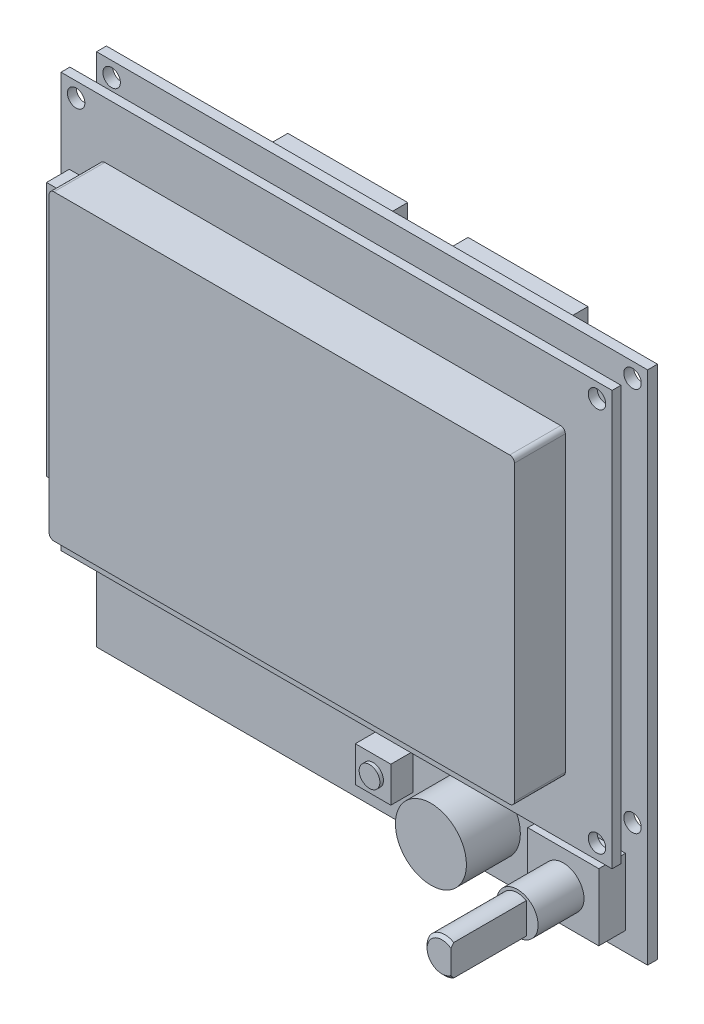
from build123d import *

# Parameters (mm, degrees)
SKETCH1_W            = 93.1
SKETCH1_H            = 87.1
SKETCH1_R            = 1.475
BOSS_EXTRUDE1_DEPTH  = 1.67
BOSS_EXTRUDE2_START  = 4.5
SKETCH2_W            = 93.1
SKETCH2_H            = 70
SKETCH2_R            = 1.475
BOSS_EXTRUDE2_DEPTH  = 1.5
BOSS_EXTRUDE3_DEPTH  = 8.6
SKETCH4_W            = 5.2
SKETCH4_H            = 43
BOSS_EXTRUDE4_DEPTH  = 3.85
SKETCH5_W            = 6
SKETCH5_H            = 6
BOSS_EXTRUDE5_DEPTH  = 3.78
SKETCH6_R            = 1.75
BOSS_EXTRUDE6_DEPTH  = 0.6
SKETCH7_R            = 6
BOSS_EXTRUDE7_DEPTH  = 9.11
SKETCH8_W            = 12
SKETCH8_H            = 11.3
BOSS_EXTRUDE8_DEPTH  = 4.5
SKETCH9_R            = 3.5
BOSS_EXTRUDE10_DEPTH = 7.75
BOSS_EXTRUDE11_DEPTH = 12.75
CHAMFER1_SIZE        = 0.5
SKETCH12_W           = 20.25
SKETCH12_H           = 8.95
BOSS_EXTRUDE12_DEPTH = 9
SKETCH13_W           = 26
SKETCH13_H           = 26.4
BOSS_EXTRUDE13_DEPTH = 3.5


with BuildPart() as part:
    # Sketch1 → Boss-Extrude1 (new body)
    with BuildSketch(Plane.XY):
        with Locations((46.55, -43.55)):
            Rectangle(SKETCH1_W, SKETCH1_H)
        with Locations((2.55, -2.5)):
            Circle(SKETCH1_R, mode=Mode.SUBTRACT)
        with Locations((90.55, -2.5)):
            Circle(SKETCH1_R, mode=Mode.SUBTRACT)
        with Locations((2.55, -67.5)):
            Circle(SKETCH1_R, mode=Mode.SUBTRACT)
        with Locations((90.55, -67.5)):
            Circle(SKETCH1_R, mode=Mode.SUBTRACT)
    extrude(amount=BOSS_EXTRUDE1_DEPTH)

    # Sketch5 → Boss-Extrude5 (add)
    with BuildSketch(Plane.XY.offset(1.67)):
        with Locations((50.5, -78.6)):
            Rectangle(SKETCH5_W, SKETCH5_H)
    extrude(amount=BOSS_EXTRUDE5_DEPTH)

    # Sketch6 → Boss-Extrude6 (add)
    with BuildSketch(Plane.XY.offset(5.45)):
        with Locations((50.5, -78.6)):
            Circle(SKETCH6_R)
    extrude(amount=BOSS_EXTRUDE6_DEPTH)

    # Sketch7 → Boss-Extrude7 (add)
    with BuildSketch(Plane.XY.offset(1.67)):
        with Locations((65.6, -78.6)):
            Circle(SKETCH7_R)
    extrude(amount=BOSS_EXTRUDE7_DEPTH)

    # Sketch8 → Boss-Extrude8 (add)
    with BuildSketch(Plane.XY.offset(1.67)):
        with Locations((83.35, -78.25)):
            Rectangle(SKETCH8_W, SKETCH8_H)
    extrude(amount=BOSS_EXTRUDE8_DEPTH)

    # Sketch9 → Boss-Extrude10 (add)
    with BuildSketch(Plane.XY.offset(6.17)):
        with Locations((83.35, -78.25)):
            Circle(SKETCH9_R)
    extrude(amount=BOSS_EXTRUDE10_DEPTH)

    # Sketch11 → Boss-Extrude11 (add)
    with BuildSketch(Plane.XY.offset(13.92)):
        with BuildLine():
            Line((84.85, -75.651923789), (84.85, -80.848076211))
            ThreePointArc((84.85, -80.848076211), (80.35, -78.25), (84.85, -75.651923789))
        make_face()
    extrude(amount=BOSS_EXTRUDE11_DEPTH)

    # Chamfer1
    chamfer1_edges = [part.edges().sort_by_distance(p)[0] for p in [
        (80.35, -78.25, 26.67),
    ]]
    chamfer(chamfer1_edges, length=CHAMFER1_SIZE)

    # Sketch12 → Boss-Extrude12 (add)
    with BuildSketch(Plane(origin=(0, 0, 0), x_dir=(-1, 0, 0), z_dir=(0, 0, -1))):
        with Locations((-62.225, -10.925)):
            Rectangle(SKETCH12_W, SKETCH12_H)
        with Locations((-31.775, -10.925)):
            Rectangle(SKETCH12_W, SKETCH12_H)
    extrude(amount=BOSS_EXTRUDE12_DEPTH)

    # Sketch13 → Boss-Extrude13 (add)
    with BuildSketch(Plane(origin=(0, 0, 0), x_dir=(-1, 0, 0), z_dir=(0, 0, -1))):
        with Locations((-13, -35.4)):
            Rectangle(SKETCH13_W, SKETCH13_H)
    extrude(amount=BOSS_EXTRUDE13_DEPTH)


with BuildPart() as body_2:
    # Sketch2 → Boss-Extrude2 (new body)
    with BuildSketch(Plane.XY.offset(1.67).offset(BOSS_EXTRUDE2_START)):
        with Locations((46.55, -35)):
            Rectangle(SKETCH2_W, SKETCH2_H)
        with Locations((2.55, -2.5)):
            Circle(SKETCH2_R, mode=Mode.SUBTRACT)
        with Locations((2.55, -67.5)):
            Circle(SKETCH2_R, mode=Mode.SUBTRACT)
        with Locations((90.55, -67.5)):
            Circle(SKETCH2_R, mode=Mode.SUBTRACT)
        with Locations((90.55, -2.5)):
            Circle(SKETCH2_R, mode=Mode.SUBTRACT)
    extrude(amount=BOSS_EXTRUDE2_DEPTH)

    # Sketch3 → Boss-Extrude3 (add)
    with BuildSketch(Plane.XY.offset(7.67)):
        with BuildLine():
            Line((7.4, -9.5), (84.4, -9.5))
            ThreePointArc((84.4, -9.5), (84.965685425, -9.734314575), (85.2, -10.3))
            Line((85.2, -10.3), (85.2, -59.8))
            ThreePointArc((85.2, -59.8), (84.965685425, -60.365685425), (84.4, -60.6))
            Line((84.4, -60.6), (7.4, -60.6))
            ThreePointArc((7.4, -60.6), (6.834314575, -60.365685425), (6.6, -59.8))
            Line((6.6, -59.8), (6.6, -10.3))
            ThreePointArc((6.6, -10.3), (6.834314575, -9.734314575), (7.4, -9.5))
        make_face()
    extrude(amount=BOSS_EXTRUDE3_DEPTH)

    # Sketch4 → Boss-Extrude4 (add)
    with BuildSketch(Plane.XY.offset(7.67)):
        with Locations((4, -35)):
            Rectangle(SKETCH4_W, SKETCH4_H)
    extrude(amount=BOSS_EXTRUDE4_DEPTH)


solid = Compound([part.part, body_2.part])
